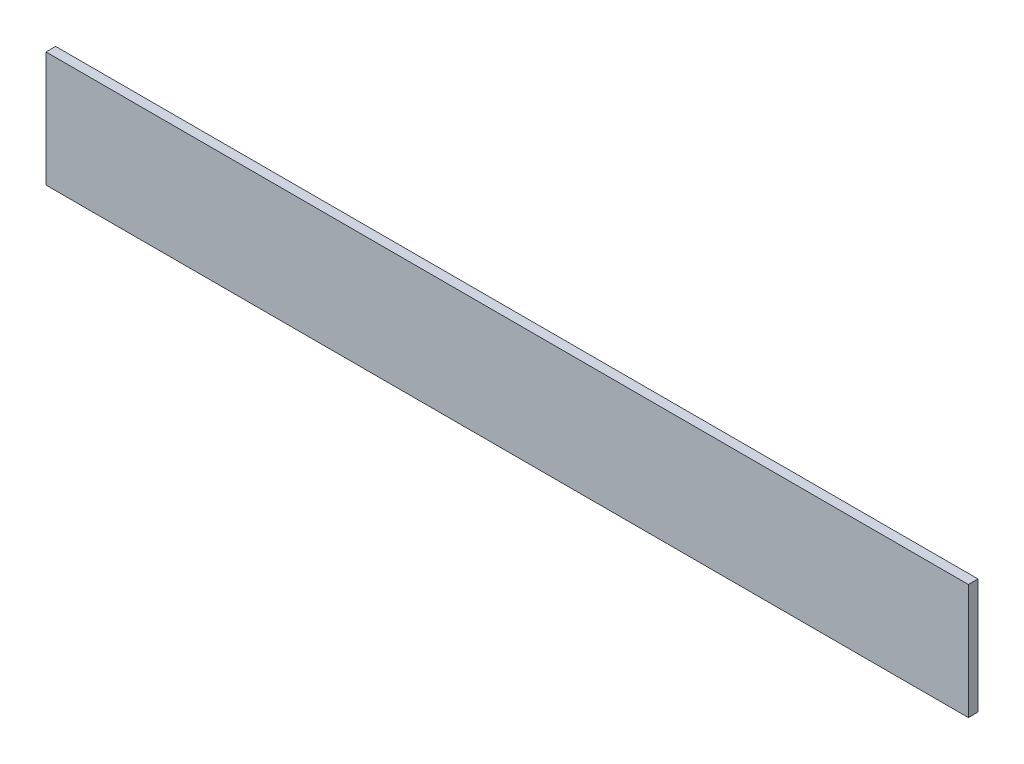
from build123d import *

# Parameters (mm, degrees)
SKETCH1_W           = 6.35
SKETCH1_H           = 76.2
BOSS_EXTRUDE1_DEPTH = 609.6


with BuildPart() as part:
    # Sketch1 → Boss-Extrude1 (new body)
    with BuildSketch(Plane(origin=(0, 0, 0), x_dir=(0, 0, -1), z_dir=(1, 0, 0))):
        Rectangle(SKETCH1_W, SKETCH1_H)
    extrude(amount=BOSS_EXTRUDE1_DEPTH)


solid = part.part
